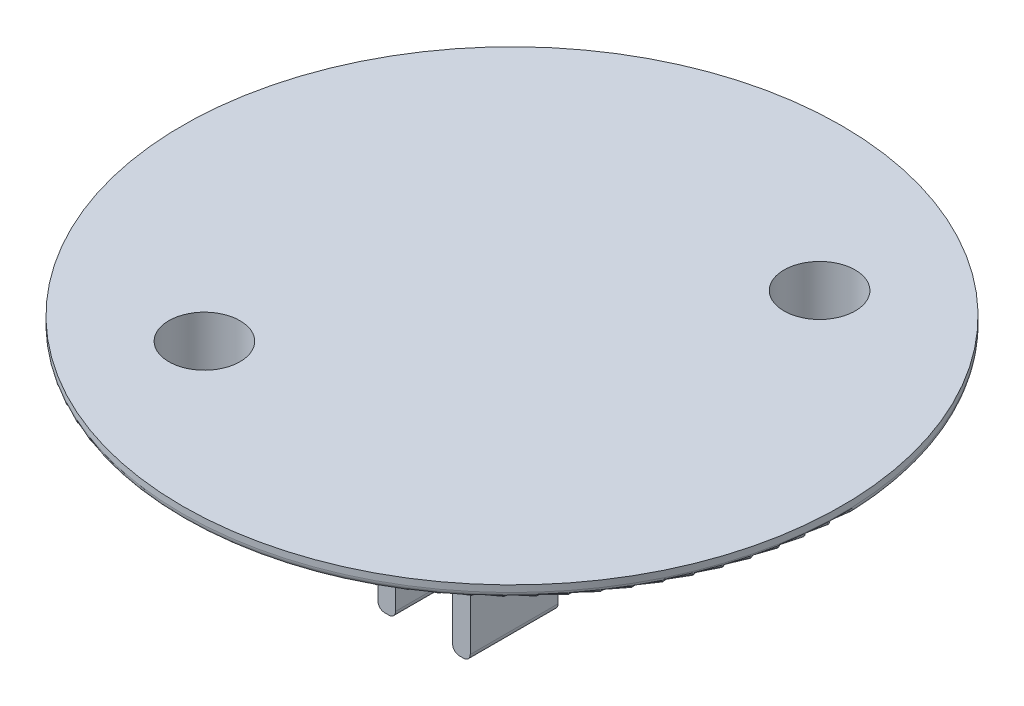
from build123d import *

# Parameters (mm, degrees)
SKETCH1_R           = 75
BOSS_EXTRUDE1_DEPTH = 3
SKETCH2_R           = 11.1
SKETCH2_R_2         = 8.1
EXTRUDE_THIN1_DEPTH = 11
SKETCH2_2_R         = 8.1
CUT_EXTRUDE1_DEPTH  = 4
SKETCH3_W           = 4
SKETCH3_H           = 20
BOSS_EXTRUDE2_DEPTH = 20
SKETCH6_R           = 2.5
CUT_EXTRUDE2_DEPTH  = 21
SKETCH7_R           = 11.1
SKETCH7_R_2         = 5.5
BOSS_EXTRUDE3_DEPTH = 3
FILLET1_R           = 3
FILLET2_R           = 2
SKETCH8_R           = 1.5
CUT_EXTRUDE3_DEPTH  = 21
FILLET3_R           = 1.5
FILLET4_R           = 1.5


with BuildPart() as part:
    # Sketch1 → Boss-Extrude1 (new body)
    with BuildSketch(Plane(origin=(0, 0, 0), x_dir=(1, 0, 0), z_dir=(0, 1, 0))):
        Circle(SKETCH1_R)
    extrude(amount=BOSS_EXTRUDE1_DEPTH)

    # Sketch2 → Extrude-Thin1 (add)
    with BuildSketch(Plane.XZ):
        with Locations((-30, 40)):
            Circle(SKETCH2_R)
        with Locations((-30, 40)):
            Circle(SKETCH2_R_2, mode=Mode.SUBTRACT)
        with Locations((30, -40)):
            Circle(SKETCH2_R)
        with Locations((30, -40)):
            Circle(SKETCH2_R_2, mode=Mode.SUBTRACT)
    extrude(amount=EXTRUDE_THIN1_DEPTH)

    # Sketch2_2 → Cut-Extrude1 (cut, through all)
    with BuildSketch(Plane.XZ):
        with Locations((-30, 40)):
            Circle(SKETCH2_2_R)
        with Locations((30, -40)):
            Circle(SKETCH2_2_R)
    extrude(amount=-CUT_EXTRUDE1_DEPTH, mode=Mode.SUBTRACT)

    # Sketch3 → Boss-Extrude2 (add)
    with BuildSketch(Plane.XZ):
        with Locations((21.5, 40)):
            Rectangle(SKETCH3_W, SKETCH3_H)
        with Locations((-38.5, -40)):
            Rectangle(SKETCH3_W, SKETCH3_H)
        with Locations((-21.5, -40)):
            Rectangle(SKETCH3_W, SKETCH3_H)
        with Locations((38.5, 40)):
            Rectangle(SKETCH3_W, SKETCH3_H)
    extrude(amount=BOSS_EXTRUDE2_DEPTH)

    # Sketch6 → Cut-Extrude2 (cut)
    with BuildSketch(Plane.ZY.offset(40.5)):
        with Locations((-40, -10)):
            Circle(SKETCH6_R)
    extrude(amount=-CUT_EXTRUDE2_DEPTH, mode=Mode.SUBTRACT)

    # Sketch7 → Boss-Extrude3 (add)
    with BuildSketch(Plane.XZ.offset(11)):
        with Locations((30, -40)):
            Circle(SKETCH7_R)
        with Locations((30, -40)):
            Circle(SKETCH7_R_2, mode=Mode.SUBTRACT)
        with Locations((-30, 40)):
            Circle(SKETCH7_R)
        with Locations((-30, 40)):
            Circle(SKETCH7_R_2, mode=Mode.SUBTRACT)
    extrude(amount=BOSS_EXTRUDE3_DEPTH)

    # Fillet1
    fillet1_edges = [part.edges().sort_by_distance(p)[0] for p in [
        (18.9, 0, -40),
        (-40.5, 0, -40),
        (-19.5, 0, -40),
        (19.5, 0, 40),
        (-41.1, 0, 40),
        (40.5, 0, 40),
    ]]
    fillet(fillet1_edges, radius=FILLET1_R)

    # Fillet2
    fillet2_edges = [part.edges().sort_by_distance(p)[0] for p in [
        (-36.5, 0, -40),
        (-23.5, 0, -40),
        (23.5, 0, 40),
        (36.5, 0, 40),
    ]]
    fillet(fillet2_edges, radius=FILLET2_R)

    # Sketch8 → Cut-Extrude3 (cut)
    with BuildSketch(Plane(origin=(40.5, 0, 0), x_dir=(0, 0, -1), z_dir=(1, 0, 0))):
        with Locations((-40, -10)):
            Circle(SKETCH8_R)
    extrude(amount=-CUT_EXTRUDE3_DEPTH, mode=Mode.SUBTRACT)

    # Fillet3
    fillet3_edges = [part.edges().sort_by_distance(p)[0] for p in [
        (-40.5, -20, -40),
        (-36.5, -20, -40),
        (-23.5, -20, -40),
        (-19.5, -20, -40),
        (19.5, -20, 40),
        (23.5, -20, 40),
        (36.5, -20, 40),
        (40.5, -20, 40),
        (18.9, -14, -40),
        (-41.1, -14, 40),
    ]]
    fillet(fillet3_edges, radius=FILLET3_R)

    # Fillet4
    fillet4_edges = [part.edges().sort_by_distance(p)[0] for p in [
        (-75, 0, 0),
    ]]
    fillet(fillet4_edges, radius=FILLET4_R)


solid = part.part
